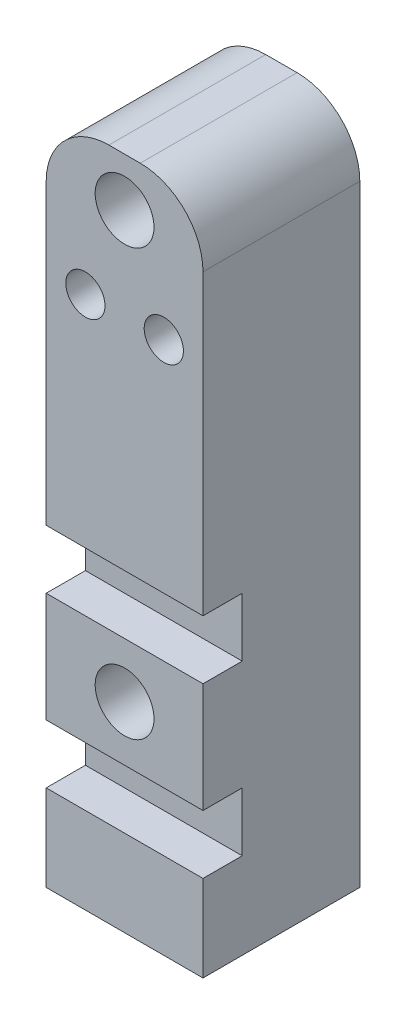
from build123d import *

# Parameters (mm, degrees)
BOSS_EXTRUDE1_DEPTH = 12.7
SKETCH2_R           = 4.7625
CUT_EXTRUDE1_DEPTH  = 26.4
FILLET1_R           = 10.16
SKETCH3_R           = 3.175
CUT_EXTRUDE2_DEPTH  = 26.4
SKETCH4_R           = 3.175
CUT_EXTRUDE3_DEPTH  = 17.78
SKETCH6_R           = 4.7625
CUT_EXTRUDE4_DEPTH  = 16.51


with BuildPart() as part:
    # Sketch1 → Boss-Extrude1 (new body, symmetric)
    with BuildSketch(Plane(origin=(0, 0, 0), x_dir=(0, 0, -1), z_dir=(1, 0, 0))):
        Polygon((-12.7, 0), (12.7, 0), (12.7, 109.22), (-12.7, 109.22), (-12.7, 50.8), (-6.35, 50.8), (-6.35, 41.275), (-12.7, 41.275), (-12.7, 23.495), (-6.35, 23.495), (-6.35, 13.97), (-12.7, 13.97), align=None)
    extrude(amount=BOSS_EXTRUDE1_DEPTH, both=True)

    # Sketch2 → Cut-Extrude1 (cut, through all)
    with BuildSketch(Plane.XY.offset(12.7)):
        with Locations((0, 32.385)):
            Circle(SKETCH2_R)
    extrude(amount=-CUT_EXTRUDE1_DEPTH, mode=Mode.SUBTRACT)

    # Fillet1
    fillet1_edges = [part.edges().sort_by_distance(p)[0] for p in [
        (-12.7, 109.22, 0),
        (12.7, 109.22, 0),
    ]]
    fillet(fillet1_edges, radius=FILLET1_R)

    # Sketch3 → Cut-Extrude2 (cut, through all)
    with BuildSketch(Plane.XY.offset(12.7)):
        with Locations((-6.35, 86.36)):
            Circle(SKETCH3_R)
        with Locations((6.35, 86.36)):
            Circle(SKETCH3_R)
    extrude(amount=-CUT_EXTRUDE2_DEPTH, mode=Mode.SUBTRACT)

    # Sketch4 → Cut-Extrude3 (cut)
    with BuildSketch(Plane.XZ):
        Circle(SKETCH4_R)
    extrude(amount=-CUT_EXTRUDE3_DEPTH, mode=Mode.SUBTRACT)

    # Sketch6 → Cut-Extrude4 (cut)
    with BuildSketch(Plane.XY.offset(12.7)):
        with Locations((0, 101.346)):
            Circle(SKETCH6_R)
    extrude(amount=-CUT_EXTRUDE4_DEPTH, mode=Mode.SUBTRACT)


solid = part.part
